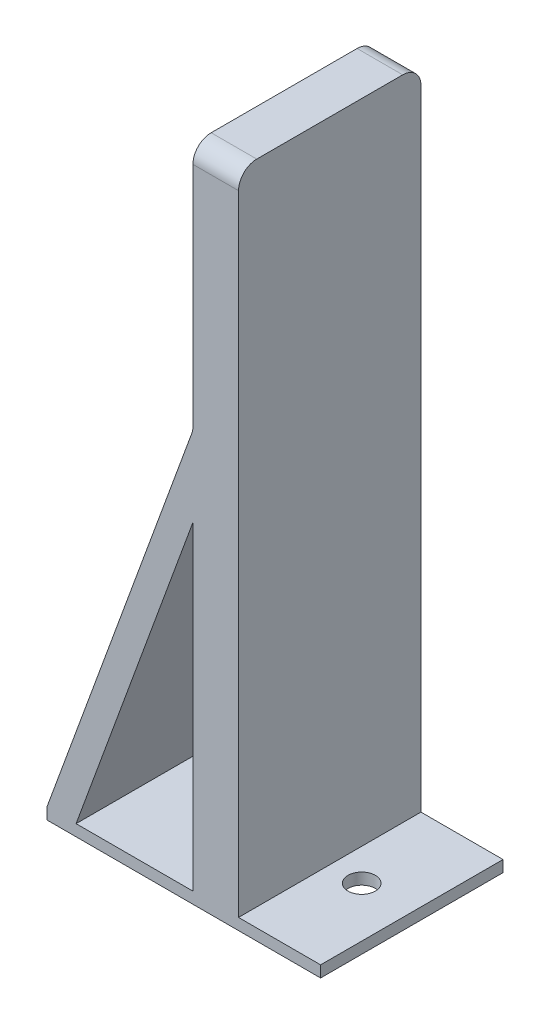
from build123d import *

# Parameters (mm, degrees)
SKETCH1_W           = 30
SKETCH1_H           = 20
BOSS_EXTRUDE1_DEPTH = 1.25
SKETCH2_W           = 5
SKETCH2_H           = 20
BOSS_EXTRUDE2_DEPTH = 71
BOSS_EXTRUDE3_DEPTH = 20
CUT_EXTRUDE2_REACH  = 3.25
SKETCH4_R           = 1.5
FILLET1_R           = 2


with BuildPart() as part:
    # Sketch1 → Boss-Extrude1 (new body)
    with BuildSketch(Plane(origin=(0, 0, 0), x_dir=(1, 0, 0), z_dir=(0, 1, 0))):
        Rectangle(SKETCH1_W, SKETCH1_H)
    extrude(amount=BOSS_EXTRUDE1_DEPTH)

    # Sketch2 → Boss-Extrude2 (add)
    with BuildSketch(Plane(origin=(0, 1.25, 0), x_dir=(1, 0, 0), z_dir=(0, 1, 0))):
        with Locations((3.5, 0)):
            Rectangle(SKETCH2_W, SKETCH2_H)
    extrude(amount=BOSS_EXTRUDE2_DEPTH)

    # Sketch3 → Boss-Extrude3 (add)
    with BuildSketch(Plane.XY.offset(10)):
        Polygon((1, 36.25), (-11.805511119, 1.25), (-15, 1.25), (1, 44.981171275), align=None)
    extrude(amount=-BOSS_EXTRUDE3_DEPTH)

    # Sketch4 → Cut-Extrude2 (cut, up to next)
    with BuildSketch(Plane(origin=(0, 1.25, 0), x_dir=(1, 0, 0), z_dir=(0, 1, 0)), mode=Mode.PRIVATE) as cut_extrude2_sk1:
        with Locations((9.5, 0)):
            Circle(SKETCH4_R)
    cut_extrude2_tool1 = extrude(cut_extrude2_sk1.sketch, amount=-CUT_EXTRUDE2_REACH, mode=Mode.PRIVATE) & part.part
    add(cut_extrude2_tool1.solids().sort_by_distance((9.5, 1.25, 0))[0], mode=Mode.SUBTRACT)

    # Fillet1
    fillet1_edges = [part.edges().sort_by_distance(p)[0] for p in [
        (3.5, 72.25, -10),
        (3.5, 72.25, 10),
        (1, 44.981171275, 0),
    ]]
    fillet(fillet1_edges, radius=FILLET1_R)


solid = part.part
